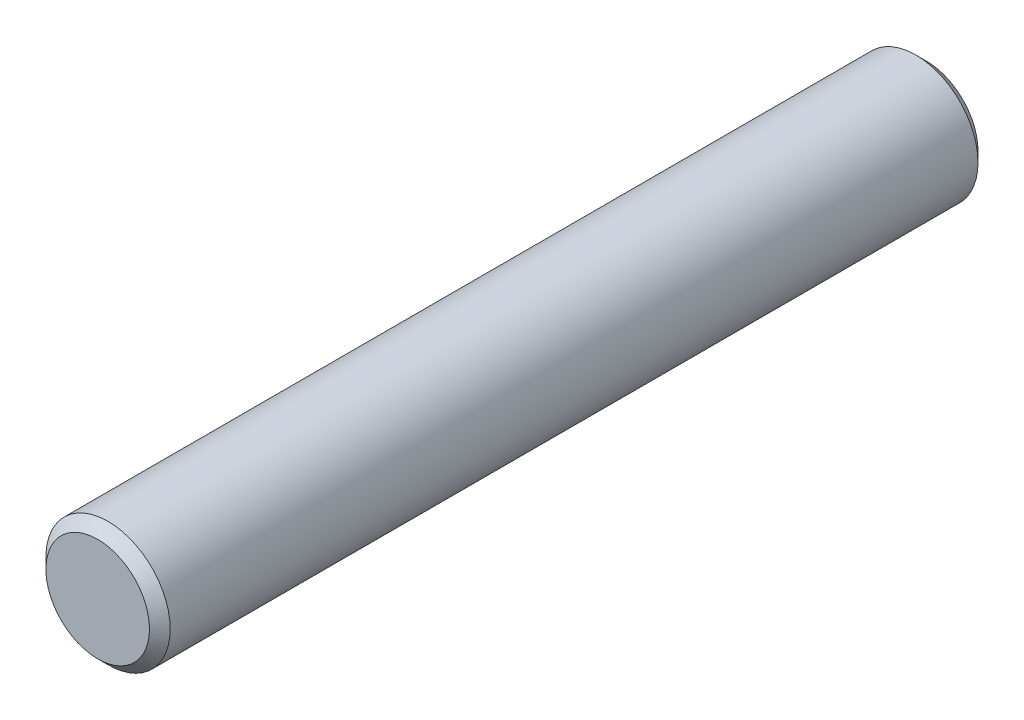
from build123d import *

# Parameters (mm, degrees)
SKETCH1_R           = 1.5
BOSS_EXTRUDE1_DEPTH = 10
CHAMFER2_SIZE       = 0.25


with BuildPart() as part:
    # Sketch1 → Boss-Extrude1 (new body, symmetric)
    with BuildSketch(Plane.XY):
        Circle(SKETCH1_R)
    extrude(amount=BOSS_EXTRUDE1_DEPTH, both=True)

    # Chamfer2
    chamfer2_edges = [part.edges().sort_by_distance(p)[0] for p in [
        (-1.5, 0, -10),
        (-1.5, 0, 10),
    ]]
    chamfer(chamfer2_edges, length=CHAMFER2_SIZE)


solid = part.part
